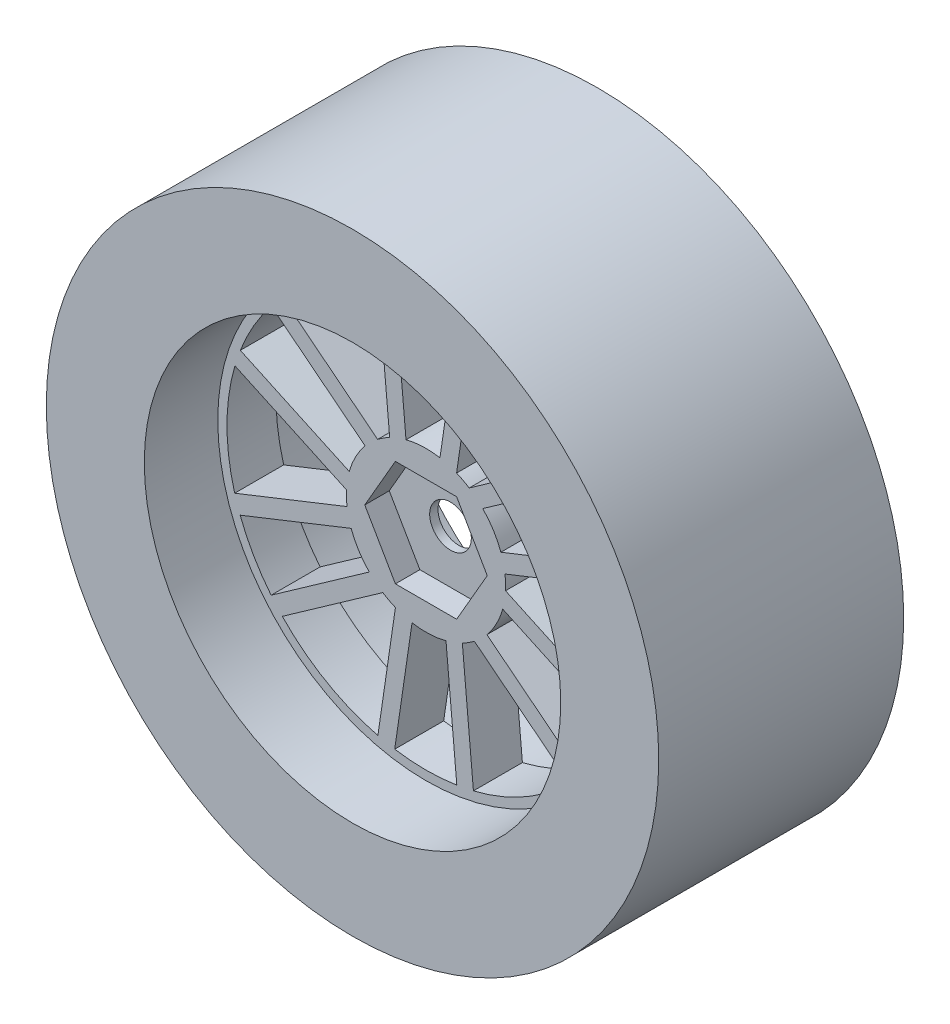
from build123d import *

# Parameters (mm, degrees)
SKETCH1_R           = 31.75
BOSS_EXTRUDE1_DEPTH = 25.4
SKETCH3_R           = 21.59
CUT_EXTRUDE1_DEPTH  = 7.62
SKETCH4_R           = 21.59
CUT_EXTRUDE2_DEPTH  = 12.7
CUT_EXTRUDE3_DEPTH  = 13.7
BOSS_EXTRUDE2_DEPTH = 5.08
CIRPATTERN1_COUNT   = 6
CUT_EXTRUDE5_DEPTH  = 2.54
SKETCH8_R           = 2.159
CUT_EXTRUDE6_DEPTH  = 2.54
CUT_EXTRUDE7_DEPTH  = 1.6764


with BuildPart() as part:
    # Sketch1 → Boss-Extrude1 (new body)
    with BuildSketch(Plane.XY):
        Circle(SKETCH1_R)
    extrude(amount=BOSS_EXTRUDE1_DEPTH)

    # Sketch3 → Cut-Extrude1 (cut)
    with BuildSketch(Plane.XY.offset(25.4)):
        Circle(SKETCH3_R)
    extrude(amount=-CUT_EXTRUDE1_DEPTH, mode=Mode.SUBTRACT)

    # Sketch4 → Cut-Extrude2 (cut)
    with BuildSketch(Plane(origin=(0, 0, 0), x_dir=(-1, 0, 0), z_dir=(0, 0, -1))):
        Circle(SKETCH4_R)
    extrude(amount=-CUT_EXTRUDE2_DEPTH, mode=Mode.SUBTRACT)

    # Sketch5 → Cut-Extrude3 (cut, through all)
    with BuildSketch(Plane(origin=(0, 0, 12.7), x_dir=(-1, 0, 0), z_dir=(0, 0, -1))):
        with BuildLine():
            Line((-3.169774213, 7.622175309), (-4.990334321, 20.025058542))
            ThreePointArc((-4.990334321, 20.025058542), (-12.706659311, -16.261833088), (20.6375, 0))
            ThreePointArc((20.6375, 0), (16.238120297, 12.736948436), (4.915648471, 20.043522803))
            Line((4.915648471, 20.043522803), (3.767056418, 7.345359824))
            ThreePointArc((3.767056418, 7.345359824), (7.044220174, 4.303950178), (8.255, 0))
            ThreePointArc((8.255, 0), (-4.581404745, -6.867004847), (-3.169774213, 7.622175309))
        make_face()
        with BuildLine():
            ThreePointArc((-3.245486062, 20.380707212), (-4.121747911, 20.221711115), (-4.990334321, 20.025058542))
            Line((-4.990334321, 20.025058542), (-3.169774213, 7.622175309))
            ThreePointArc((-3.169774213, 7.622175309), (-2.322085611, 7.921675543), (-1.446854472, 8.127215829))
            Line((-1.446854472, 8.127215829), (-3.245486062, 20.380707212))
        make_face()
        with BuildLine():
            ThreePointArc((3.194434326, 20.388771311), (-0.025842356, 20.63748382), (-3.245486062, 20.380707212))
            Line((-3.245486062, 20.380707212), (-1.446854472, 8.127215829))
            ThreePointArc((-1.446854472, 8.127215829), (0.320434302, 8.248778507), (2.072967036, 7.990483882))
            Line((2.072967036, 7.990483882), (3.194434326, 20.388771311))
        make_face()
        with BuildLine():
            ThreePointArc((4.915648471, 20.043522803), (4.058714067, 20.234456908), (3.194434326, 20.388771311))
            Line((3.194434326, 20.388771311), (2.072967036, 7.990483882))
            ThreePointArc((2.072967036, 7.990483882), (2.937773774, 7.714564813), (3.767056418, 7.345359824))
            Line((3.767056418, 7.345359824), (4.915648471, 20.043522803))
        make_face()
    extrude(amount=-CUT_EXTRUDE3_DEPTH, mode=Mode.SUBTRACT)

    # Sketch5_3 → Boss-Extrude2 (add)
    with BuildSketch(Plane(origin=(0, 0, 12.7), x_dir=(-1, 0, 0), z_dir=(0, 0, -1))):
        with BuildLine():
            ThreePointArc((-3.245486062, 20.380707212), (-4.121747911, 20.221711115), (-4.990334321, 20.025058542))
            Line((-4.990334321, 20.025058542), (-3.169774213, 7.622175309))
            ThreePointArc((-3.169774213, 7.622175309), (-2.322085611, 7.921675543), (-1.446854472, 8.127215829))
            Line((-1.446854472, 8.127215829), (-3.245486062, 20.380707212))
        make_face()
        with BuildLine():
            ThreePointArc((4.915648471, 20.043522803), (4.058714067, 20.234456908), (3.194434326, 20.388771311))
            Line((3.194434326, 20.388771311), (2.072967036, 7.990483882))
            ThreePointArc((2.072967036, 7.990483882), (2.937773774, 7.714564813), (3.767056418, 7.345359824))
            Line((3.767056418, 7.345359824), (4.915648471, 20.043522803))
        make_face()
    boss_extrude2 = extrude(amount=-BOSS_EXTRUDE2_DEPTH)

    # CirPattern1: Boss-Extrude2 ×6 about axis
    cirpattern1_axis = Axis((0, 0, 0), (0, 0, 1))
    for i in range(1, CIRPATTERN1_COUNT):
        add(boss_extrude2.rotate(cirpattern1_axis, i * 360 / CIRPATTERN1_COUNT))

    # Sketch7 → Cut-Extrude5 (cut)
    with BuildSketch(Plane.XY.offset(17.78)):
        Polygon((6.35, 0), (3.175, 5.499261314), (-3.175, 5.499261314), (-6.35, 0), (-3.175, -5.499261314), (3.175, -5.499261314), align=None)
    extrude(amount=-CUT_EXTRUDE5_DEPTH, mode=Mode.SUBTRACT)

    # Sketch8 → Cut-Extrude6 (cut)
    with BuildSketch(Plane.XY.offset(15.24)):
        Circle(SKETCH8_R)
    extrude(amount=-CUT_EXTRUDE6_DEPTH, mode=Mode.SUBTRACT)

    # Sketch9 → Cut-Extrude7 (cut)
    with BuildSketch(Plane(origin=(0, 0, 12.7), x_dir=(-1, 0, 0), z_dir=(0, 0, -1))):
        Polygon((7.020387337, 0), (2.169418994, 6.676785124), (-5.679612663, 4.126480142), (-5.679612663, -4.126480142), (2.169418994, -6.676785124), align=None)
    extrude(amount=-CUT_EXTRUDE7_DEPTH, mode=Mode.SUBTRACT)


solid = part.part
